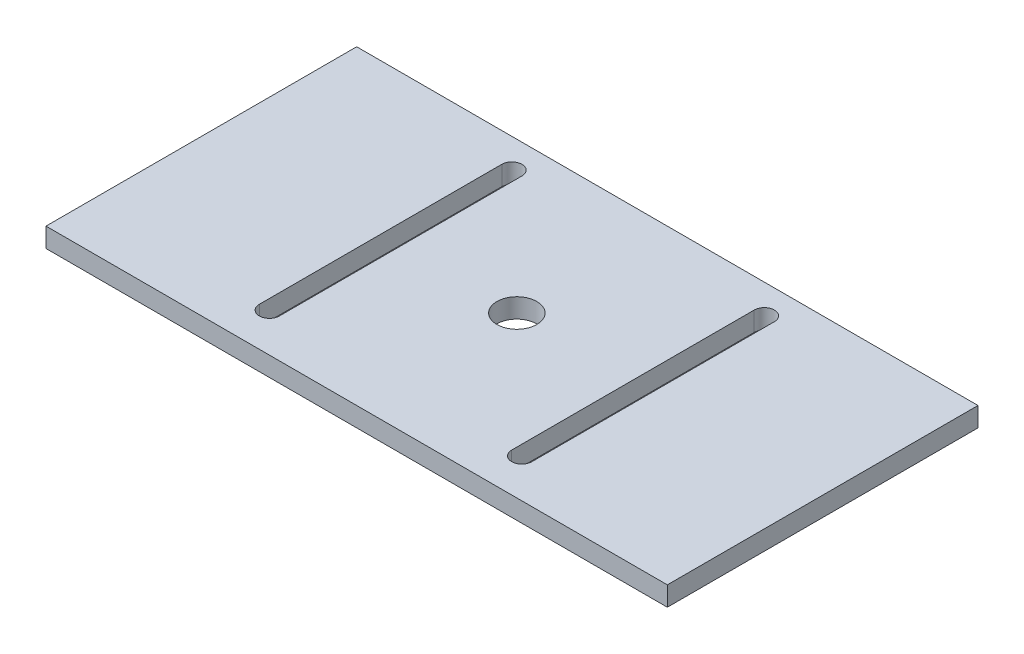
from build123d import *

# Parameters (mm, degrees)
SKETCH2_W           = 101.6
SKETCH2_H           = 50.8
SKETCH2_R           = 3.2639
BOSS_EXTRUDE1_DEPTH = 3.175


with BuildPart() as part:
    # Sketch2 → Boss-Extrude1 (new body)
    with BuildSketch(Plane(origin=(0, 0, 0), x_dir=(1, 0, 0), z_dir=(0, 1, 0))):
        with Locations((50.8, 25.4)):
            Rectangle(SKETCH2_W, SKETCH2_H)
        with Locations((50.8, 26.191302461)):
            Circle(SKETCH2_R, mode=Mode.SUBTRACT)
        with BuildLine():
            Line((28.5115, 6.363982324), (28.5115, 46.018622597))
            ThreePointArc((28.5115, 46.018622597), (30.1625, 47.669622597), (31.8135, 46.018622597))
            Line((31.8135, 46.018622597), (31.8135, 6.363982324))
            ThreePointArc((31.8135, 6.363982324), (30.1625, 4.712982324), (28.5115, 6.363982324))
        make_face(mode=Mode.SUBTRACT)
        with BuildLine():
            Line((73.0885, 6.363982324), (73.0885, 46.018622597))
            ThreePointArc((73.0885, 46.018622597), (71.4375, 47.669622597), (69.7865, 46.018622597))
            Line((69.7865, 46.018622597), (69.7865, 6.363982324))
            ThreePointArc((69.7865, 6.363982324), (71.4375, 4.712982324), (73.0885, 6.363982324))
        make_face(mode=Mode.SUBTRACT)
    extrude(amount=BOSS_EXTRUDE1_DEPTH)


solid = part.part
